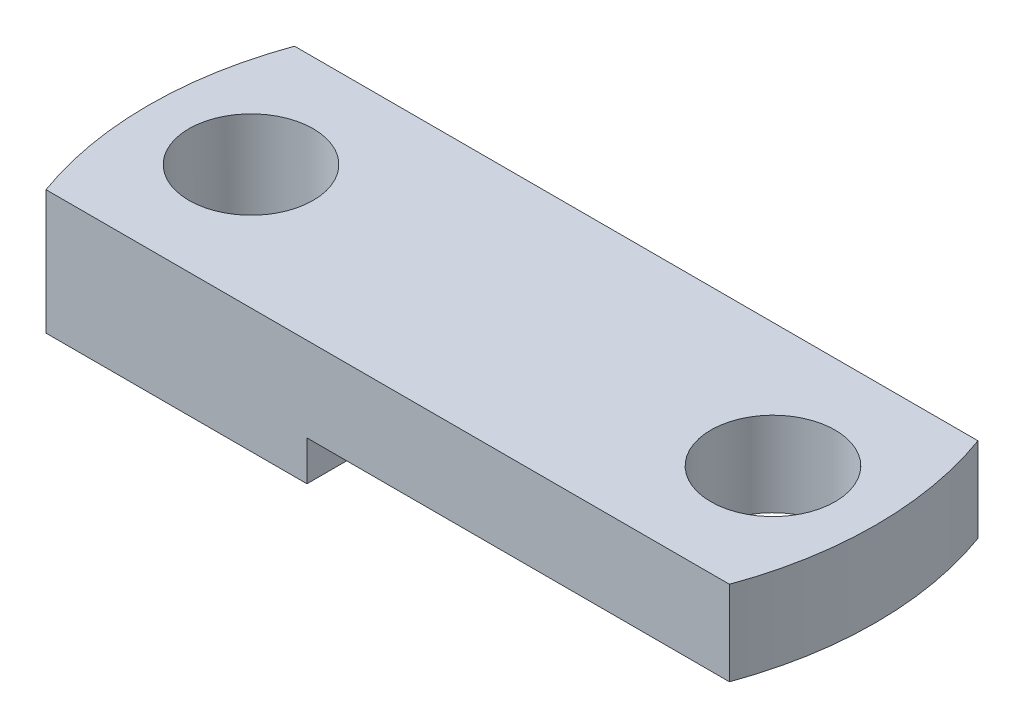
from build123d import *

# Parameters (mm, degrees)
BOSS_EXTRUDE2_DEPTH = 6.35
SKETCH4_R           = 3.175
CUT_EXTRUDE1_DEPTH  = 12.7
CUT_EXTRUDE2_DEPTH  = 2.032


with BuildPart() as part:
    # Sketch3 → Boss-Extrude2 (new body)
    with BuildSketch(Plane(origin=(0, 0, 0), x_dir=(1, 0, 0), z_dir=(0, 1, 0))):
        with BuildLine():
            Line((-17.4625, 6.35), (17.4625, 6.35))
            ThreePointArc((17.4625, 6.35), (18.581211108, 0), (17.4625, -6.35))
            Line((17.4625, -6.35), (-17.4625, -6.35))
            ThreePointArc((-17.4625, -6.35), (-18.581211108, 0), (-17.4625, 6.35))
        make_face()
    extrude(amount=BOSS_EXTRUDE2_DEPTH)

    # Sketch4 → Cut-Extrude1 (cut)
    with BuildSketch(Plane(origin=(0, 6.35, 0), x_dir=(1, 0, 0), z_dir=(0, 1, 0))):
        with Locations((13.335, 0)):
            Circle(SKETCH4_R)
        with Locations((-13.335, 0)):
            Circle(SKETCH4_R)
    extrude(amount=-CUT_EXTRUDE1_DEPTH, mode=Mode.SUBTRACT)

    # Sketch5 → Cut-Extrude2 (cut)
    with BuildSketch(Plane.XZ):
        with BuildLine():
            Line((17.4625, 6.35), (-4.1275, 6.35))
            Line((-4.1275, 6.35), (-4.1275, -6.35))
            Line((-4.1275, -6.35), (17.4625, -6.35))
            ThreePointArc((17.4625, -6.35), (18.581211108, 0), (17.4625, 6.35))
        make_face()
    extrude(amount=-CUT_EXTRUDE2_DEPTH, mode=Mode.SUBTRACT)


solid = part.part
